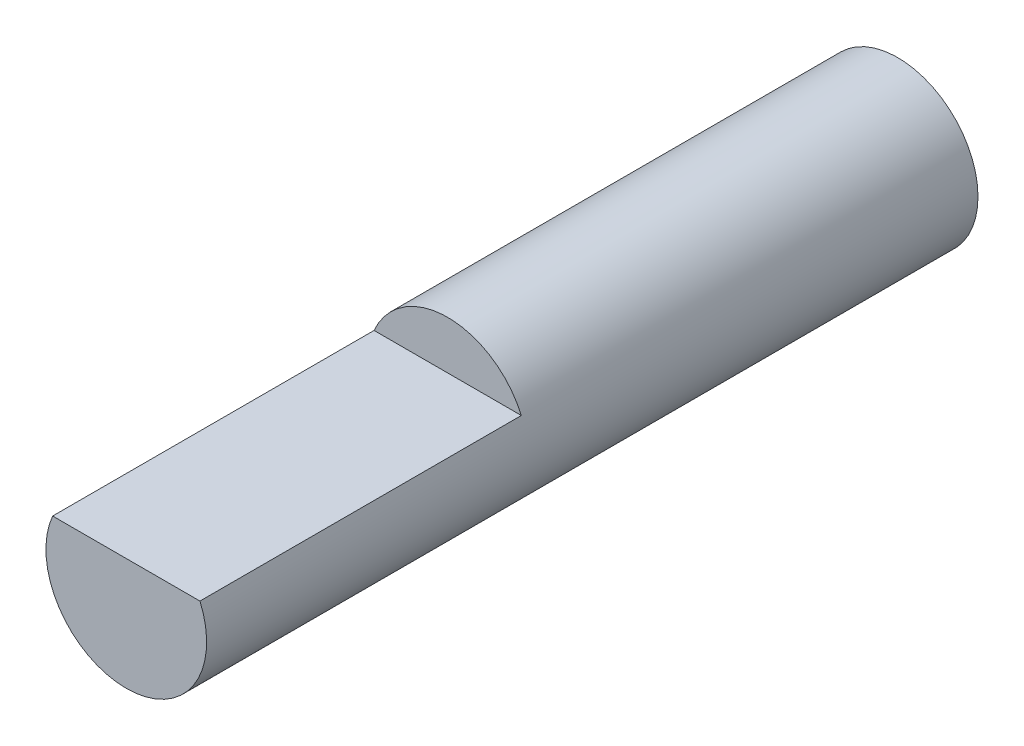
from build123d import *

# Parameters (mm, degrees)
CROQUIS2_R              = 2.5
SALIENTE_EXTRUIR1_DEPTH = 24
CORTAR_EXTRUIR1_DEPTH   = 10


with BuildPart() as part:
    # Croquis2 → Saliente-Extruir1 (new body)
    with BuildSketch(Plane.XY):
        Circle(CROQUIS2_R)
    extrude(amount=SALIENTE_EXTRUIR1_DEPTH)

    # Croquis3 → Cortar-Extruir1 (cut)
    with BuildSketch(Plane.XY.offset(24)):
        with BuildLine():
            Line((-2.291287847, 1), (2.291287847, 1))
            ThreePointArc((2.291287847, 1), (0, 2.5), (-2.291287847, 1))
        make_face()
    extrude(amount=-CORTAR_EXTRUIR1_DEPTH, mode=Mode.SUBTRACT)


solid = part.part
